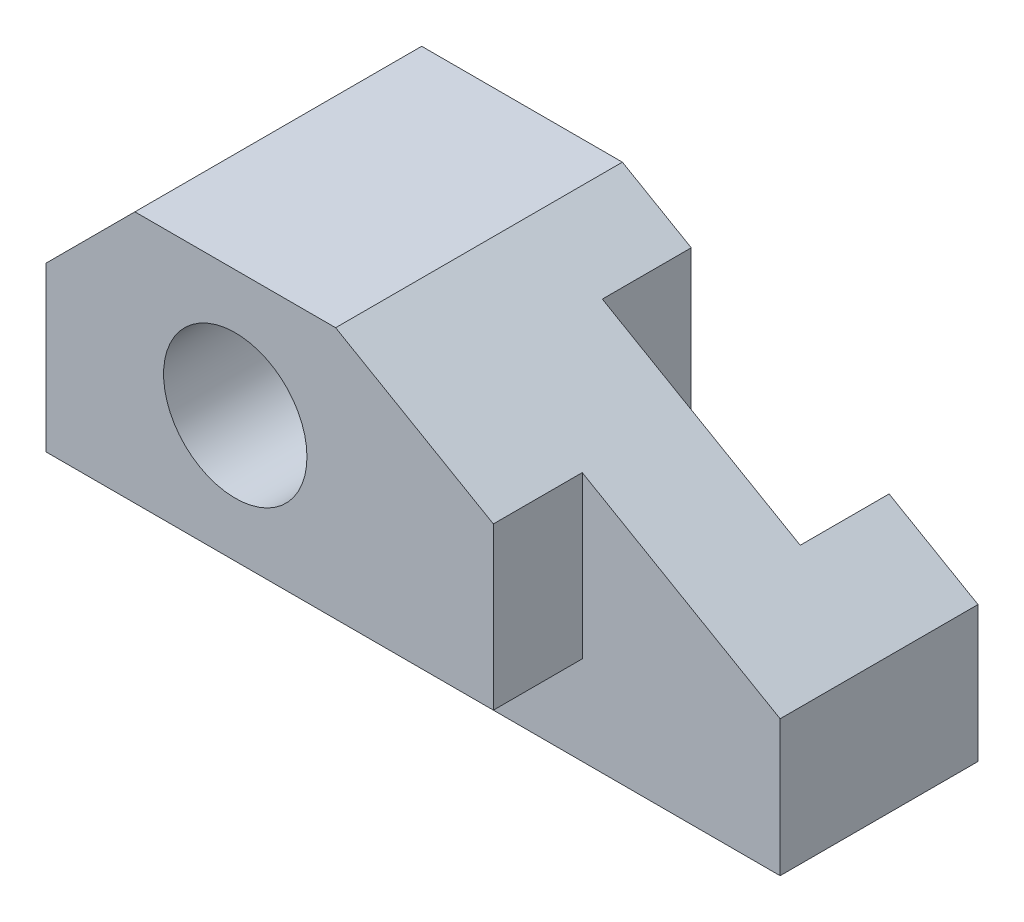
from build123d import *

# Parameters (mm, degrees)
SKETCH1_R               = 12.7
BOSS_EXTRUDE1_DEPTH     = 25.4
CUT_EXTRUDE1_START      = 25.4
CUT_EXTRUDE1_DEPTH      = 15.748
CUT_EXTRUDE2_DEPTH      = 105.037110148
CUT_EXTRUDE2_DEPTH_BACK = 105.037110148
SKETCH2_W               = 35.052
SKETCH2_H               = 15.748


with BuildPart() as part:
    # Sketch1 → Boss-Extrude1 (new, symmetric)
    with BuildSketch(Plane.XY):
        Polygon((-33.528, 0), (80.772, 0), (80.772, 24.083551843), (17.78, 60.452), (-17.78, 60.452), (-33.528, 44.704), align=None)
        with Locations((0, 38.1)):
            Circle(SKETCH1_R, mode=Mode.SUBTRACT)
    extrude(amount=BOSS_EXTRUDE1_DEPTH, both=True)

    # Sketch1_4 → Cut-Extrude1 (cut)
    with BuildSketch(Plane.XY.offset(CUT_EXTRUDE1_START)):
        Polygon((-33.528, 15.748), (-33.528, 0), (80.772, 0), (80.772, 24.083551843), (45.72, 44.320833479), (45.72, 15.748), align=None)
    extrude(amount=-CUT_EXTRUDE1_DEPTH, mode=Mode.SUBTRACT)

    # Sketch2 → Cut-Extrude2 (cut, two sides: drawn at the far end of the back side and taken through both)
    with BuildSketch(Plane(origin=(0, 0, 0), x_dir=(1, 0, 0), z_dir=(0, 1, 0)).offset(-CUT_EXTRUDE2_DEPTH_BACK)):
        with Locations((47.498, 17.526)):
            Rectangle(SKETCH2_W, SKETCH2_H)
    extrude(amount=CUT_EXTRUDE2_DEPTH + CUT_EXTRUDE2_DEPTH_BACK, mode=Mode.SUBTRACT)


solid = part.part
